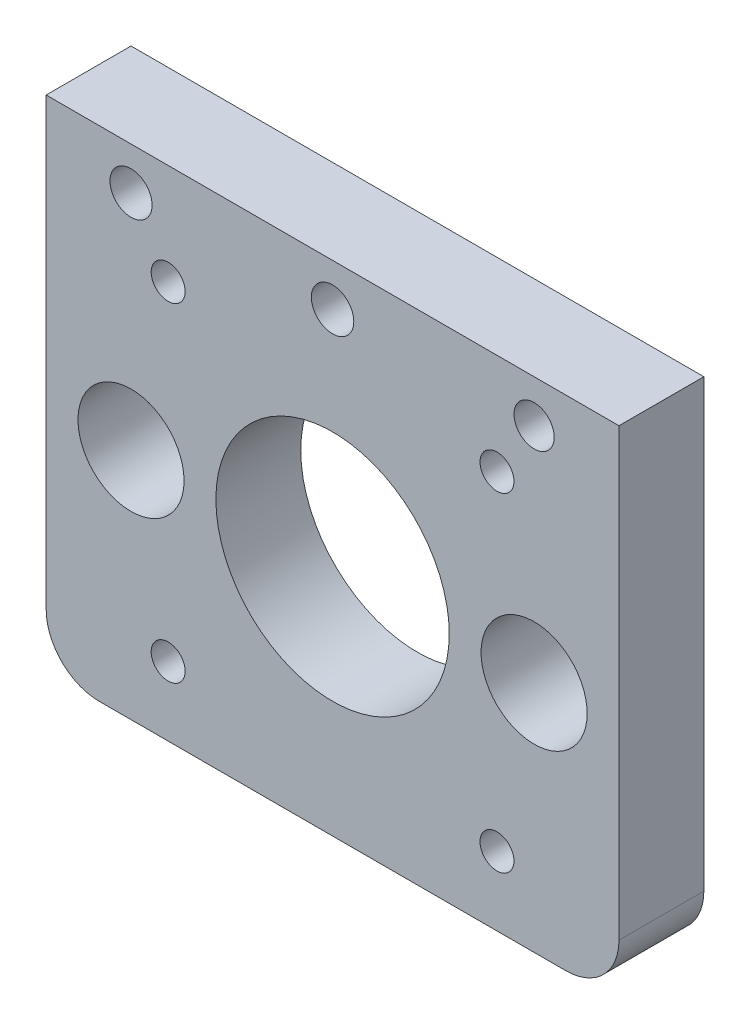
from build123d import *

# Parameters (mm, degrees)
SKETCH1_R           = 5
SKETCH1_R_2         = 11
SKETCH1_R_3         = 2
SKETCH1_R_4         = 1.984633097
SKETCH1_R_5         = 1.894356903
SKETCH1_R_6         = 1.6
BOSS_EXTRUDE1_DEPTH = 8


with BuildPart() as part:
    # Sketch1 → Boss-Extrude1 (new body)
    with BuildSketch(Plane.XY):
        with BuildLine():
            Line((-22, -22), (22, -22))
            ThreePointArc((22, -22), (25.535533906, -20.535533906), (27, -17))
            Line((27, -17), (27, 25))
            Line((27, 25), (-27, 25))
            Line((-27, 25), (-27, -17))
            ThreePointArc((-27, -17), (-25.535533906, -20.535533906), (-22, -22))
        make_face()
        with Locations((-19, 0)):
            Circle(SKETCH1_R, mode=Mode.SUBTRACT)
        with Locations((19, 0)):
            Circle(SKETCH1_R, mode=Mode.SUBTRACT)
        Circle(SKETCH1_R_2, mode=Mode.SUBTRACT)
        with Locations((0, 21)):
            Circle(SKETCH1_R_3, mode=Mode.SUBTRACT)
        with Locations((-19, 21)):
            Circle(SKETCH1_R_4, mode=Mode.SUBTRACT)
        with Locations((19, 21)):
            Circle(SKETCH1_R_5, mode=Mode.SUBTRACT)
        with Locations((-15.5, 15.5)):
            Circle(SKETCH1_R_6, mode=Mode.SUBTRACT)
        with Locations((15.5, 15.5)):
            Circle(SKETCH1_R_6, mode=Mode.SUBTRACT)
        with Locations((15.5, -15.5)):
            Circle(SKETCH1_R_6, mode=Mode.SUBTRACT)
        with Locations((-15.5, -15.5)):
            Circle(SKETCH1_R_6, mode=Mode.SUBTRACT)
    extrude(amount=BOSS_EXTRUDE1_DEPTH)


solid = part.part
